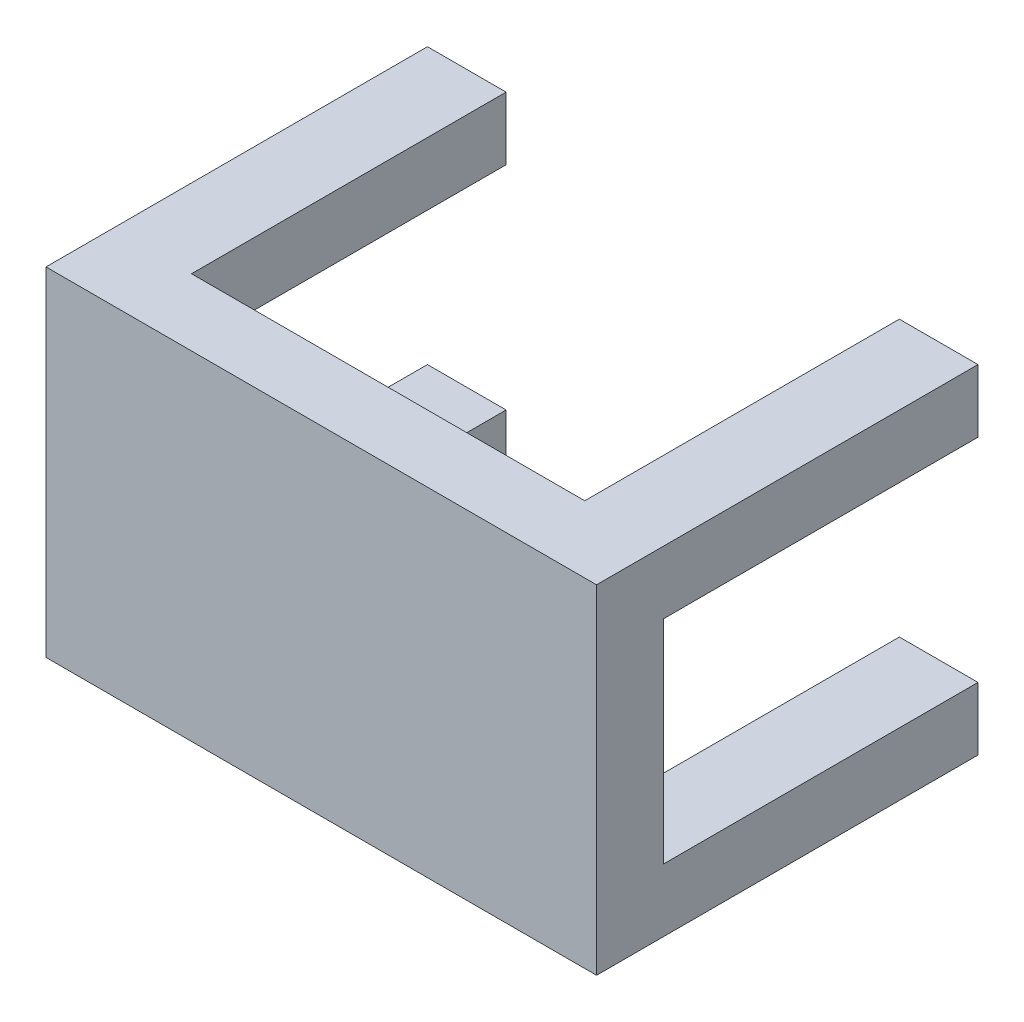
from build123d import *

# Parameters (mm, degrees)
SKETCH_1_W             = 70
SKETCH_1_H             = 43
EXTRUDE_1_DEPTH        = 48.5
SKETCH_2_W             = 50
SKETCH_2_H             = 27
SKETCH_2_H_2           = 8
SKETCH_2_W_2           = 10
CUT_EXTRUDE_1_DEPTH    = 40
HOLE_WIZARD_M3_1_D     = 2.5
HOLE_WIZARD_M3_1_DEPTH = 15
HOLE_WIZARD_M3_1_TIP   = 0.751075774


with BuildPart() as part:
    # 草图1 → 凸台-拉伸1 (new body)
    with BuildSketch(Plane.XY):
        Rectangle(SKETCH_1_W, SKETCH_1_H)
    extrude(amount=EXTRUDE_1_DEPTH)

    # 草图2 → 切除-拉伸1 (cut)
    with BuildSketch(Plane(origin=(0, 0, 0), x_dir=(-1, 0, 0), z_dir=(0, 0, -1))):
        Rectangle(SKETCH_2_W, SKETCH_2_H)
        with Locations((0, -17.5)):
            Rectangle(SKETCH_2_W, SKETCH_2_H_2)
        with Locations((-30, 0)):
            Rectangle(SKETCH_2_W_2, SKETCH_2_H)
        with Locations((0, 17.5)):
            Rectangle(SKETCH_2_W, SKETCH_2_H_2)
        with Locations((30, 0)):
            Rectangle(SKETCH_2_W_2, SKETCH_2_H)
    extrude(amount=-CUT_EXTRUDE_1_DEPTH, mode=Mode.SUBTRACT)

    # M3 螺纹孔1
    with Locations(Plane(origin=(0, 0, 0), x_dir=(-1, 0, 0), z_dir=(0, 0, -1))):
        with Locations((-30, 17.5), (30, 17.5), (30, -17.5), (-30, -17.5)):
            Hole(HOLE_WIZARD_M3_1_D / 2, depth=HOLE_WIZARD_M3_1_DEPTH)
            with Locations((0, 0, -(HOLE_WIZARD_M3_1_DEPTH + HOLE_WIZARD_M3_1_TIP / 2))):  # 118° drill point
                Cone(0, HOLE_WIZARD_M3_1_D / 2, HOLE_WIZARD_M3_1_TIP, mode=Mode.SUBTRACT)


solid = part.part
